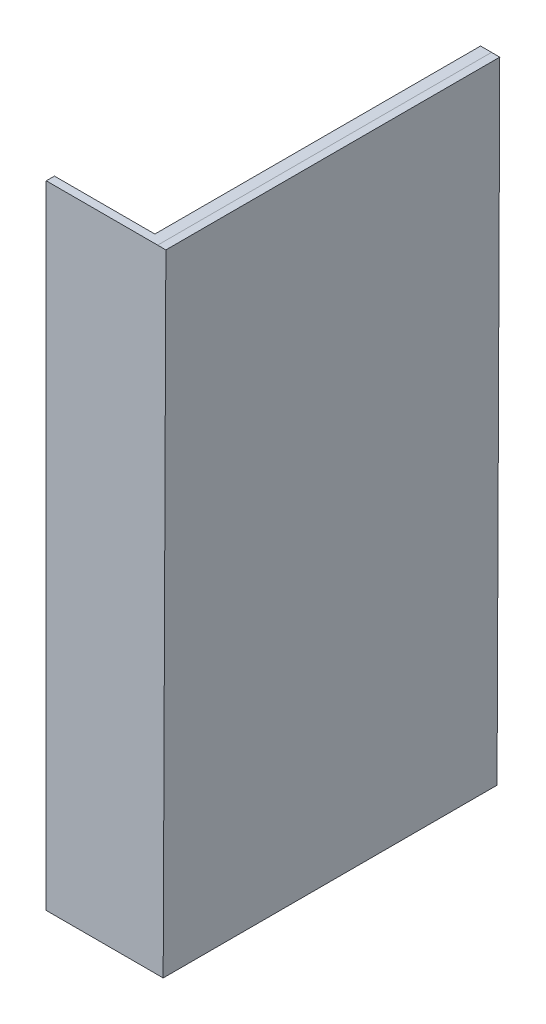
from build123d import *

# Parameters (mm, degrees)
BOSS_EXTRUDE1_DEPTH = 150
SKETCH2_W           = 150
SKETCH2_H           = 11550.267170743
BOSS_EXTRUDE2_DEPTH = 150
BOSS_EXTRUDE3_DEPTH = 5953


with BuildPart() as part:
    # Sketch1 → Boss-Extrude1 (new body)
    with BuildSketch(Plane.XY):
        Polygon((-1606.841446163, 1223.697519379), (429.510216102, 1223.697519379), (380.2634, -10326.464664185), (-1606.841446163, -10326.464664185), align=None)
    extrude(amount=BOSS_EXTRUDE1_DEPTH)

    # Sketch2 → Boss-Extrude2 (add)
    with BuildSketch(Plane(origin=(424.284982455, -1.809038191, 0), x_dir=(0, 0, -1), z_dir=(0.99999091, -0.004263695, 0))):
        with Locations((-75, -4549.615888349)):
            Rectangle(SKETCH2_W, SKETCH2_H)
    extrude(amount=BOSS_EXTRUDE2_DEPTH)

    # Sketch3 → Boss-Extrude3 (add)
    with BuildSketch(Plane(origin=(0, 0, 0), x_dir=(-1, 0, 0), z_dir=(0, 0, -1))):
        Polygon((-228.364442926, -10326.464664185), (-228.364442926, 1223.697519379), (-429.510216102, 1223.697519379), (-579.508852664, 1223.057965132), (-530.262036562, -10327.104218432), (-380.2634, -10326.464664185), align=None)
    extrude(amount=BOSS_EXTRUDE3_DEPTH)


solid = part.part
